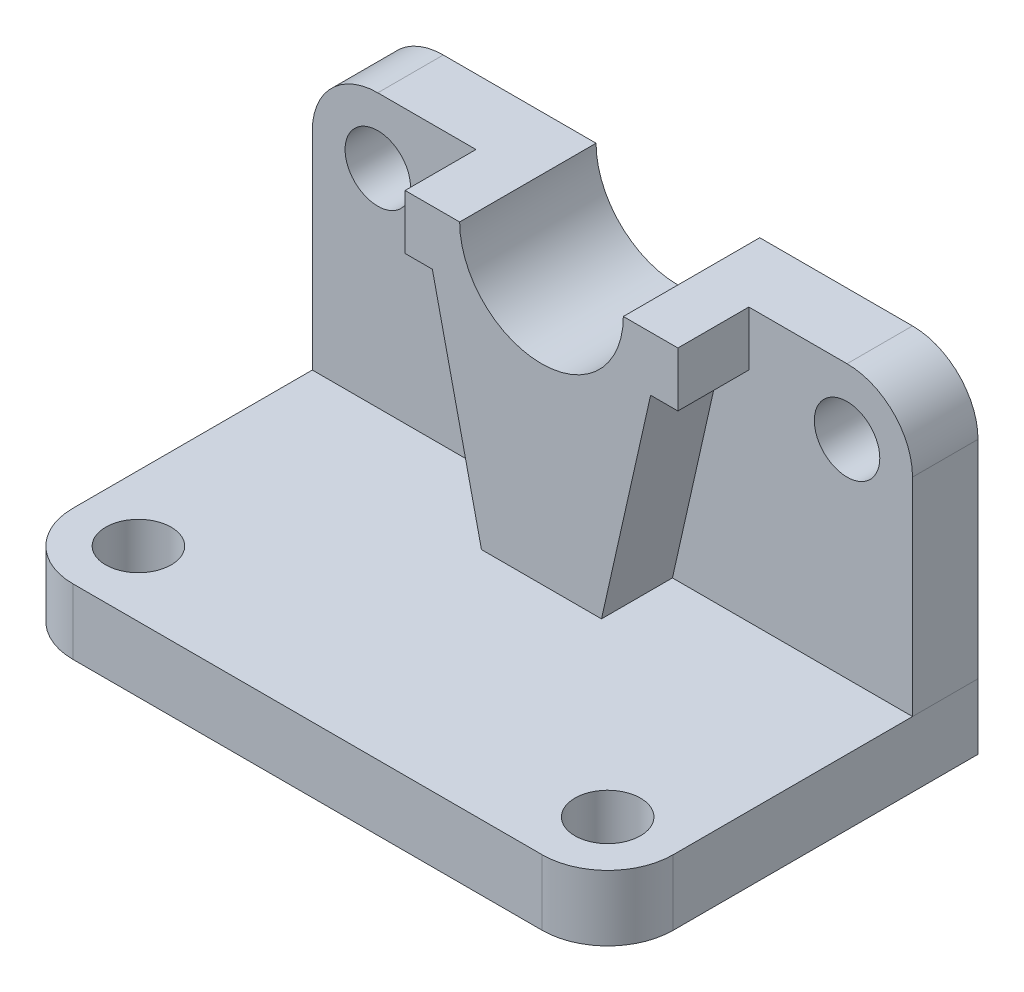
from build123d import *

# Parameters (mm, degrees)
SKETCH2_R             = 6
BOSS_EXTRUDE1_DEPTH   = 12
SKETCH14_R            = 6
BOSS_EXTRUDE9_DEPTH   = 12
BOSS_EXTRUDE9_2_DEPTH = 12
BOSS_EXTRUDE10_DEPTH  = 25


with BuildPart() as part:
    # Sketch2 → Boss-Extrude1 (new body)
    with BuildSketch(Plane(origin=(0, 0, 0), x_dir=(1, 0, 0), z_dir=(0, 1, 0))):
        with BuildLine():
            Line((-12, -67.868332512), (-98, -67.868332512))
            ThreePointArc((-98, -67.868332512), (-106.485281374, -64.353613886), (-110, -55.868332512))
            Line((-110, -55.868332512), (-110, 0))
            Line((-110, 0), (0, 0))
            Line((0, 0), (0, -55.868332512))
            ThreePointArc((0, -55.868332512), (-3.514718626, -64.353613886), (-12, -67.868332512))
        make_face()
        with Locations((-98, -55.868332512)):
            Circle(SKETCH2_R, mode=Mode.SUBTRACT)
        with Locations((-12, -55.868332512)):
            Circle(SKETCH2_R, mode=Mode.SUBTRACT)
    extrude(amount=BOSS_EXTRUDE1_DEPTH)


with BuildPart() as body_2:
    # Sketch14 → Boss-Extrude9 (new body)
    with BuildSketch(Plane.XY):
        with BuildLine():
            Line((-80, 52), (-80, 62))
            Line((-80, 62), (-98, 62))
            ThreePointArc((-98, 62), (-106.485281374, 58.485281374), (-110, 50))
            Line((-110, 50), (-110, 12))
            Line((-110, 12), (-66, 12))
            Line((-66, 12), (-75, 52))
            Line((-75, 52), (-80, 52))
        make_face()
        with Locations((-98, 50)):
            Circle(SKETCH14_R, mode=Mode.SUBTRACT)
    extrude(amount=BOSS_EXTRUDE9_DEPTH)



with BuildPart() as body_3:
    # Sketch14 → Boss-Extrude9 2 (new body)
    with BuildSketch(Plane.XY):
        with BuildLine():
            Line((-12, 62), (-30, 62))
            Line((-30, 62), (-30, 52))
            Line((-30, 52), (-35, 52))
            Line((-35, 52), (-44, 12))
            Line((-44, 12), (0, 12))
            Line((0, 12), (0, 50))
            ThreePointArc((0, 50), (-3.514718626, 58.485281374), (-12, 62))
        make_face()
        with Locations((-12, 50)):
            Circle(SKETCH14_R, mode=Mode.SUBTRACT)
    extrude(amount=BOSS_EXTRUDE9_2_DEPTH)


with BuildPart() as body_2_1:
    add(body_2.part)

    add(body_3.part)  # Boss-Extrude10 merges body 3
    # Sketch14_8 → Boss-Extrude10 (add)
    with BuildSketch(Plane.XY):
        with BuildLine():
            Line((-70, 62), (-80, 62))
            Line((-80, 62), (-80, 52))
            Line((-80, 52), (-75, 52))
            Line((-75, 52), (-66, 12))
            Line((-66, 12), (-44, 12))
            Line((-44, 12), (-35, 52))
            Line((-35, 52), (-30, 52))
            Line((-30, 52), (-30, 62))
            Line((-30, 62), (-40, 62))
            ThreePointArc((-40, 62), (-55, 47), (-70, 62))
        make_face()
    extrude(amount=BOSS_EXTRUDE10_DEPTH)


solid = Compound([part.part, body_2_1.part])
